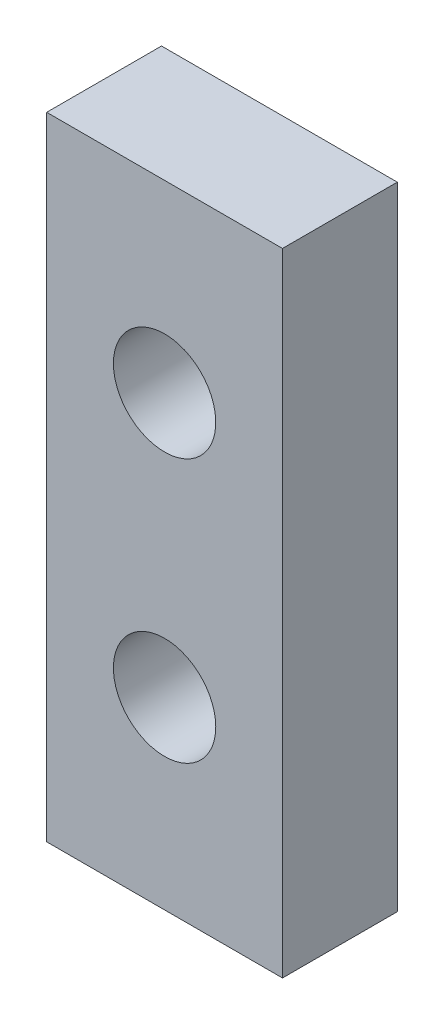
from build123d import *

# Parameters (mm, degrees)
SKETCH2_W           = 6.52
SKETCH2_H           = 17.47
BOSS_EXTRUDE1_DEPTH = 3.175
SKETCH3_R           = 1.415
CUT_EXTRUDE1_DEPTH  = 10.849286776


with BuildPart() as part:
    # Sketch2 → Boss-Extrude1 (new body)
    with BuildSketch(Plane.XY):
        Rectangle(SKETCH2_W, SKETCH2_H)
    extrude(amount=BOSS_EXTRUDE1_DEPTH)

    # Sketch3 → Cut-Extrude1 (cut, through all)
    with BuildSketch(Plane.XY.offset(3.175)):
        with Locations((0, -3.645)):
            Circle(SKETCH3_R)
        with Locations((0, 3.645)):
            Circle(SKETCH3_R)
    extrude(amount=-CUT_EXTRUDE1_DEPTH, mode=Mode.SUBTRACT)


solid = part.part
